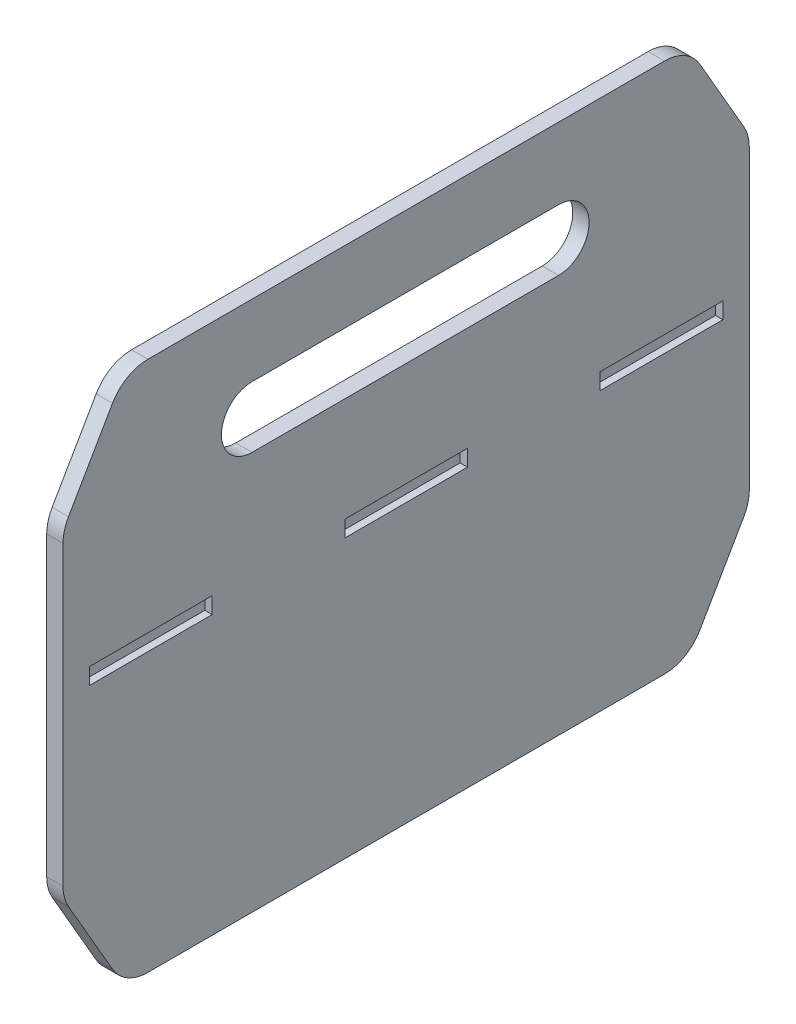
from build123d import *

# Parameters (mm, degrees)
BOSS_EXTRUDE1_DEPTH   = 10.16
SKETCH2_W             = 76.2
SKETCH2_H             = 10.16
CUT_EXTRUDE1_DEPTH    = 4.572
CHAMFER1_SIZE         = 38.1
CHAMFER1_SIZE2        = 65.991135768
CHAMFER1_PART_2_SIZE  = 38.1
CHAMFER1_PART_2_SIZE2 = 65.991135768
FILLET1_R             = 25.4


with BuildPart() as part:
    # Sketch1 → Boss-Extrude1 (new body)
    with BuildSketch(Plane(origin=(0, 0, 0), x_dir=(0, 0, -1), z_dir=(1, 0, 0))):
        Polygon((-212.802604436, 0), (-212.802604436, 254), (-212.802604436, 279.4), (213.917395564, 279.4), (213.917395564, 254), (213.917395564, 0), (213.917395564, -50.8), (-212.802604436, -50.8), align=None)
        with BuildLine():
            Line((-95.25, 234.95), (95.25, 234.95))
            ThreePointArc((95.25, 234.95), (114.3, 215.9), (95.25, 196.85))
            Line((95.25, 196.85), (-95.25, 196.85))
            ThreePointArc((-95.25, 196.85), (-114.3, 215.9), (-95.25, 234.95))
        make_face(mode=Mode.SUBTRACT)
    extrude(amount=-BOSS_EXTRUDE1_DEPTH)

    # Sketch2 → Cut-Extrude1 (cut)
    with BuildSketch(Plane(origin=(0, 0, 0), x_dir=(0, 0, -1), z_dir=(1, 0, 0))):
        with Locations((-158.192604436, 127)):
            Rectangle(SKETCH2_W, SKETCH2_H)
        with Locations((0.557395564, 127)):
            Rectangle(SKETCH2_W, SKETCH2_H)
        with Locations((159.307395564, 127)):
            Rectangle(SKETCH2_W, SKETCH2_H)
    extrude(amount=-CUT_EXTRUDE1_DEPTH, mode=Mode.SUBTRACT)

    # Chamfer1
    chamfer1_edges = [part.edges().sort_by_distance(p)[0] for p in [
        (-5.08, 279.4, 212.802604436),
        (-5.08, 279.4, -213.917395564),
    ]]
    chamfer1_side = [part.faces().sort_by_distance(p)[0] for p in [
        (-5.08, 279.4, -0.557395564),
    ]]
    chamfer(chamfer1_edges, length=CHAMFER1_SIZE, length2=CHAMFER1_SIZE2, reference=chamfer1_side[0])

    # Chamfer1 part 2
    chamfer1_part_2_edges = [part.edges().sort_by_distance(p)[0] for p in [
        (-5.08, -50.8, -213.917395564),
        (-5.08, -50.8, 212.802604436),
    ]]
    chamfer1_part_2_side = [part.faces().sort_by_distance(p)[0] for p in [
        (-5.08, -50.8, -0.557395564),
    ]]
    chamfer(chamfer1_part_2_edges, length=CHAMFER1_PART_2_SIZE, length2=CHAMFER1_PART_2_SIZE2, reference=chamfer1_part_2_side[0])

    # Fillet1
    fillet1_edges = [part.edges().sort_by_distance(p)[0] for p in [
        (-5.08, -50.8, 174.702604436),
        (-5.08, -50.8, -175.817395564),
        (-5.08, 213.408864232, -213.917395564),
        (-5.08, 15.191135768, -213.917395564),
        (-5.08, 279.4, -175.817395564),
        (-5.08, 279.4, 174.702604436),
        (-5.08, 15.191135768, 212.802604436),
        (-5.08, 213.408864232, 212.802604436),
    ]]
    fillet(fillet1_edges, radius=FILLET1_R)


solid = part.part
